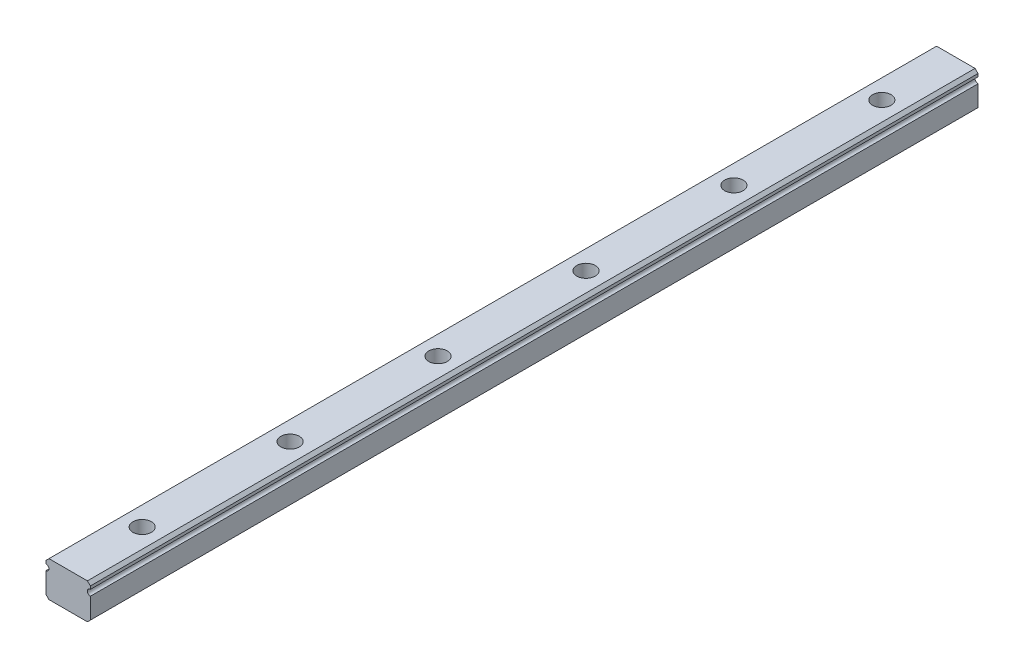
from build123d import *

# Parameters (mm, degrees)
BOSS_EXTRUDE1_DEPTH          = 60
M1_6X0_35_TAPPED_HOLE1_D     = 1.25
M1_6X0_35_TAPPED_HOLE1_DEPTH = 2.4
LPATTERN1_COUNT              = 6
LPATTERN1_PITCH              = 10


with BuildPart() as part:
    # Sketch1 → Boss-Extrude1 (new body)
    with BuildSketch(Plane.XY):
        with BuildLine():
            Line((-1.5, 1), (-1.3, 1.2))
            Line((-1.3, 1.2), (1.3, 1.2))
            Line((1.3, 1.2), (1.5, 1))
            Line((1.5, 1), (1.5, 0.8))
            ThreePointArc((1.5, 0.8), (1.3, 0.6), (1.5, 0.4))
            Line((1.5, 0.4), (1.5, -1))
            Line((1.5, -1), (1.3, -1.2))
            Line((1.3, -1.2), (-1.3, -1.2))
            Line((-1.3, -1.2), (-1.5, -1))
            Line((-1.5, -1), (-1.5, 0.4))
            ThreePointArc((-1.5, 0.4), (-1.3, 0.6), (-1.5, 0.8))
            Line((-1.5, 0.8), (-1.5, 1))
        make_face()
    extrude(amount=BOSS_EXTRUDE1_DEPTH)

    # M1.6x0.35 Tapped Hole1
    with Locations(Plane(origin=(0, 1.2, 0), x_dir=(1, 0, 0), z_dir=(0, 1, 0))):
        with Locations((0, -5)):
            m1_6x0_35_tapped_hole1 = Hole(M1_6X0_35_TAPPED_HOLE1_D / 2, depth=M1_6X0_35_TAPPED_HOLE1_DEPTH)

    # LPattern1: M1.6x0.35 Tapped Hole1 ×6
    with Locations(*[(0, 0, i * LPATTERN1_PITCH) for i in range(1, LPATTERN1_COUNT)]):
        add(m1_6x0_35_tapped_hole1, mode=Mode.SUBTRACT)


solid = part.part
